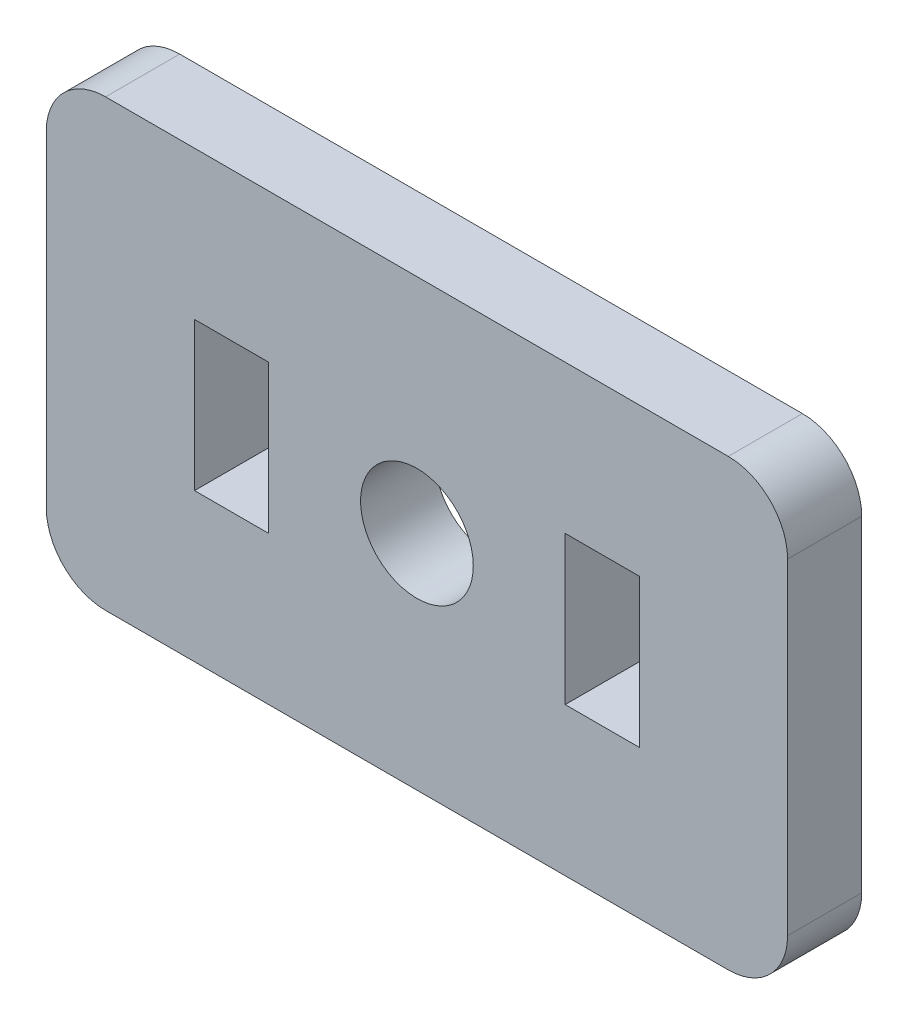
from build123d import *

# Parameters (mm, degrees)
SKETCH1_W           = 6.35
SKETCH1_H           = 19.05
SKETCH1_W_2         = 19.05
SKETCH1_R           = 2.413
BOSS_EXTRUDE1_DEPTH = 3.175
FILLET1_R           = 2.54
CUT_EXTRUDE1_REACH  = 5.175
SKETCH2_W           = 3.175
SKETCH2_H           = 6.35


with BuildPart() as part:
    # Sketch1 → Boss-Extrude1 (new body)
    with BuildSketch(Plane.XY):
        with Locations((-12.7, 0)):
            Rectangle(SKETCH1_W, SKETCH1_H)
        Rectangle(SKETCH1_W_2, SKETCH1_H)
        Circle(SKETCH1_R, mode=Mode.SUBTRACT)
        with Locations((12.7, 0)):
            Rectangle(SKETCH1_W, SKETCH1_H)
    extrude(amount=BOSS_EXTRUDE1_DEPTH)

    # Fillet1
    fillet1_edges = [part.edges().sort_by_distance(p)[0] for p in [
        (-15.875, -9.525, 1.5875),
        (-15.875, 9.525, 1.5875),
        (15.875, 9.525, 1.5875),
        (15.875, -9.525, 1.5875),
    ]]
    fillet(fillet1_edges, radius=FILLET1_R)

    # Sketch2 → Cut-Extrude1 (cut, up to next)
    with BuildSketch(Plane.XY.offset(3.175), mode=Mode.PRIVATE) as cut_extrude1_sk1:
        with Locations((7.9375, 0)):
            Rectangle(SKETCH2_W, SKETCH2_H)
    cut_extrude1_tool1 = extrude(cut_extrude1_sk1.sketch, amount=-CUT_EXTRUDE1_REACH, mode=Mode.PRIVATE) & part.part
    add(cut_extrude1_tool1.solids().sort_by_distance((7.9375, 0, 3.175))[0], mode=Mode.SUBTRACT)
    # Sketch2 → Cut-Extrude1 (cut, up to next)
    with BuildSketch(Plane.XY.offset(3.175), mode=Mode.PRIVATE) as cut_extrude1_sk2:
        with Locations((-7.9375, 0)):
            Rectangle(SKETCH2_W, SKETCH2_H)
    cut_extrude1_tool2 = extrude(cut_extrude1_sk2.sketch, amount=-CUT_EXTRUDE1_REACH, mode=Mode.PRIVATE) & part.part
    add(cut_extrude1_tool2.solids().sort_by_distance((-7.9375, 0, 3.175))[0], mode=Mode.SUBTRACT)


solid = part.part
